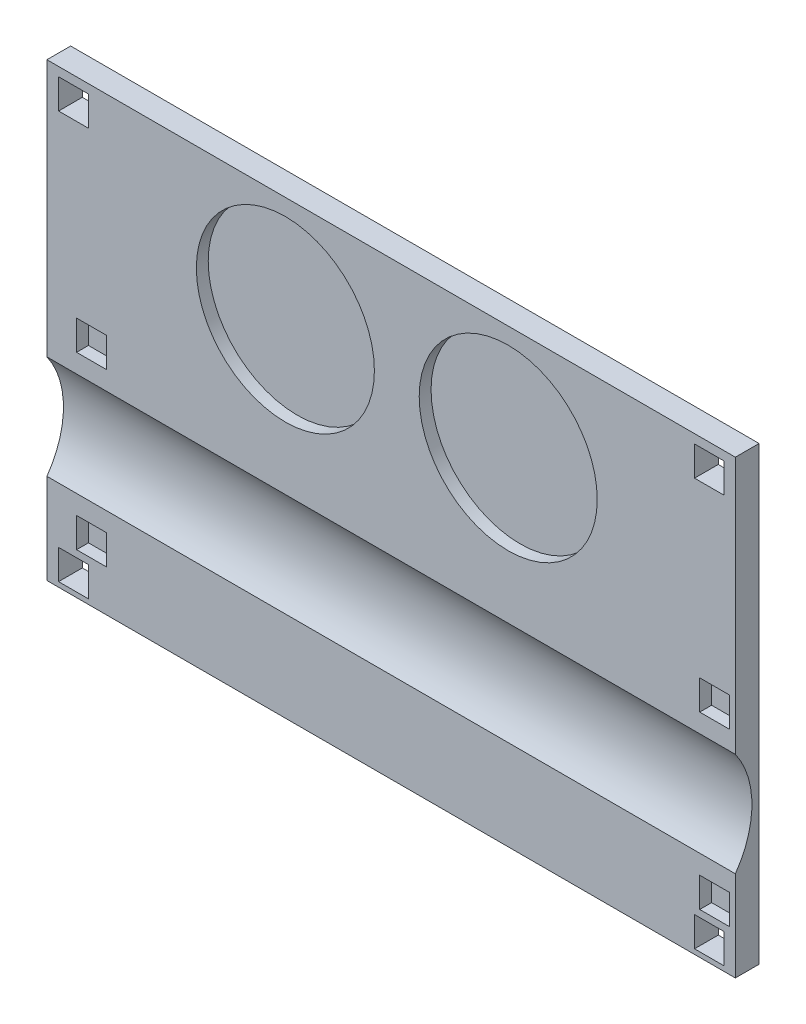
from build123d import *

# Parameters (mm, degrees)
SKETCH3_W           = 147.32
SKETCH3_H           = 96.52
BOSS_EXTRUDE1_DEPTH = 5.08
SKETCH4_R           = 19.05
SKETCH4_W           = 6.35
SKETCH4_H           = 6.35
CUT_EXTRUDE1_DEPTH  = 2.54
SKETCH6_W           = 6.35
SKETCH6_H           = 6.35
CUT_EXTRUDE3_DEPTH  = 7.62
SKETCH7_R           = 19.05
CUT_EXTRUDE4_DEPTH  = 171.45


with BuildPart() as part:
    # Sketch3 → Boss-Extrude1 (new body)
    with BuildSketch(Plane.XY):
        with Locations((85.663850978, -7.59744867)):
            Rectangle(SKETCH3_W, SKETCH3_H)
    extrude(amount=BOSS_EXTRUDE1_DEPTH)

    # Sketch4 → Cut-Extrude1 (cut)
    with BuildSketch(Plane.XY.offset(5.08)):
        with Locations((63.032517405, 18.070386575)):
            Circle(SKETCH4_R)
        with Locations((110.718650705, 18.070386575)):
            Circle(SKETCH4_R)
        with Locations((21.528850978, -43.79244867)):
            Rectangle(SKETCH4_W, SKETCH4_H)
        with Locations((154.878850978, -43.79244867)):
            Rectangle(SKETCH4_W, SKETCH4_H)
        with Locations((154.878850978, -7.21644867)):
            Rectangle(SKETCH4_W, SKETCH4_H)
        with Locations((21.528850978, -7.21644867)):
            Rectangle(SKETCH4_W, SKETCH4_H)
    extrude(amount=-CUT_EXTRUDE1_DEPTH, mode=Mode.SUBTRACT)

    # Sketch6 → Cut-Extrude3 (cut)
    with BuildSketch(Plane.XY):
        with Locations((17.679985474, -51.638260567)):
            Rectangle(SKETCH6_W, SKETCH6_H)
        with Locations((17.679985474, 35.579793927)):
            Rectangle(SKETCH6_W, SKETCH6_H)
        with Locations((153.766691322, 35.579793927)):
            Rectangle(SKETCH6_W, SKETCH6_H)
        with Locations((153.766691322, -51.638260567)):
            Rectangle(SKETCH6_W, SKETCH6_H)
    extrude(amount=CUT_EXTRUDE3_DEPTH, mode=Mode.SUBTRACT)

    # Sketch7 → Cut-Extrude4 (cut)
    with BuildSketch(Plane(origin=(0, 0, 0), x_dir=(0, 0, -1), z_dir=(1, 0, 0))):
        with Locations((-20.586973595, -25.47459189)):
            Circle(SKETCH7_R)
    extrude(amount=CUT_EXTRUDE4_DEPTH, mode=Mode.SUBTRACT)


solid = part.part
